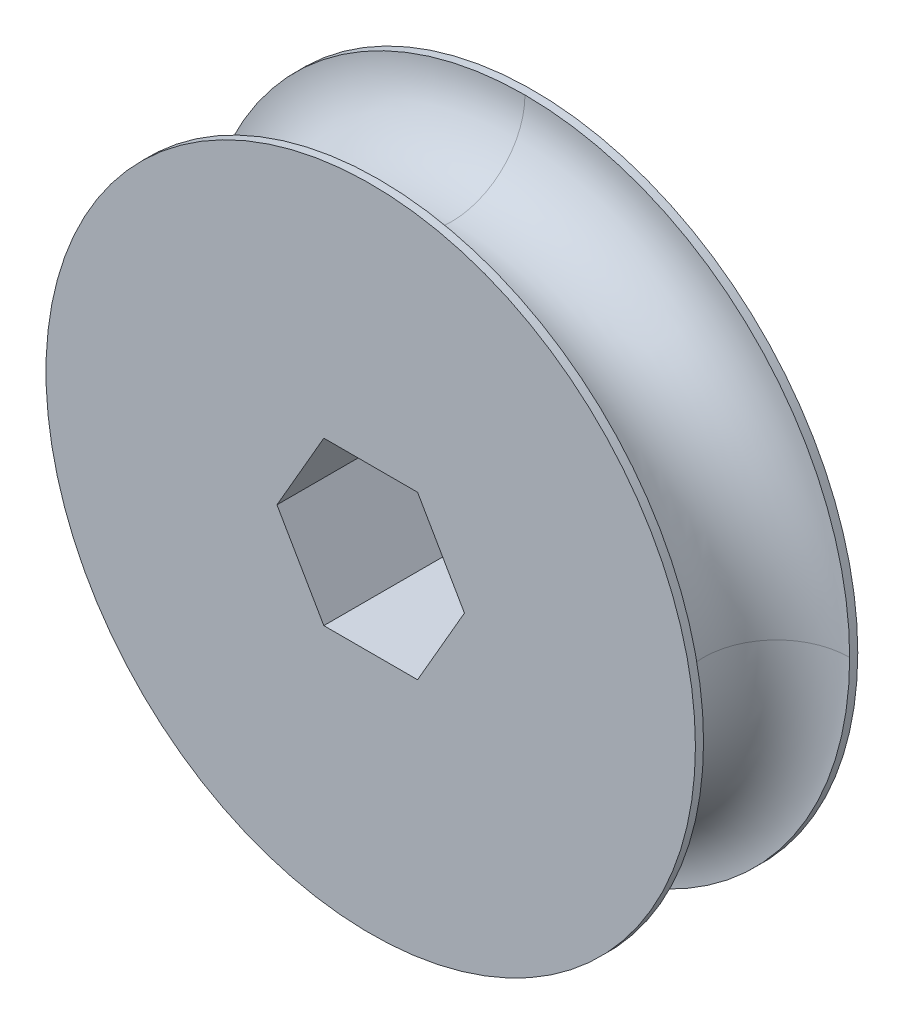
from build123d import *

# Parameters (mm, degrees)
SKETCH2_R           = 25.4
BOSS_EXTRUDE2_DEPTH = 12.7
CUT_EXTRUDE2_DEPTH  = 17.272


with BuildPart() as part:
    # Sketch2 → Boss-Extrude2 (new body)
    with BuildSketch(Plane.XY):
        Circle(SKETCH2_R)
    extrude(amount=BOSS_EXTRUDE2_DEPTH)

    # Cut-Sweep2: sweep along a curve in space
    with BuildLine() as cut_sweep2_path:
        ThreePointArc((25.4, 0, 12.7), (17.960512242, 17.960512242, 12.7), (0, 25.4, 12.7))
        ThreePointArc((0, 25.4, 12.7), (-17.960512242, 17.960512242, 12.7), (-25.4, 0, 12.7))
        ThreePointArc((-25.4, 0, 12.7), (-17.960512242, -17.960512242, 12.7), (0, -25.4, 12.7))
        ThreePointArc((0, -25.4, 12.7), (17.960512242, -17.960512242, 12.7), (25.4, 0, 12.7))
    # Sketch3 → Cut-Sweep2 (sweep, cut)
    with BuildSketch(Plane(origin=(0, 0, 0), x_dir=(0, 0, -1), z_dir=(1, 0, 0))):
        with BuildLine():
            Line((-12.065, 25.4), (-0.635, 25.4))
            ThreePointArc((-0.635, 25.4), (-6.35, 19.685), (-12.065, 25.4))
        make_face()
    sweep(path=cut_sweep2_path.line, mode=Mode.SUBTRACT)

    # Sketch22 → Cut-Extrude2 (cut)
    with BuildSketch(Plane.XY):
        Polygon((7.332348419, 0), (3.666174209, 6.35), (-3.666174209, 6.35), (-7.332348419, 0), (-3.666174209, -6.35), (3.666174209, -6.35), align=None)
    extrude(amount=CUT_EXTRUDE2_DEPTH, mode=Mode.SUBTRACT)


solid = part.part
